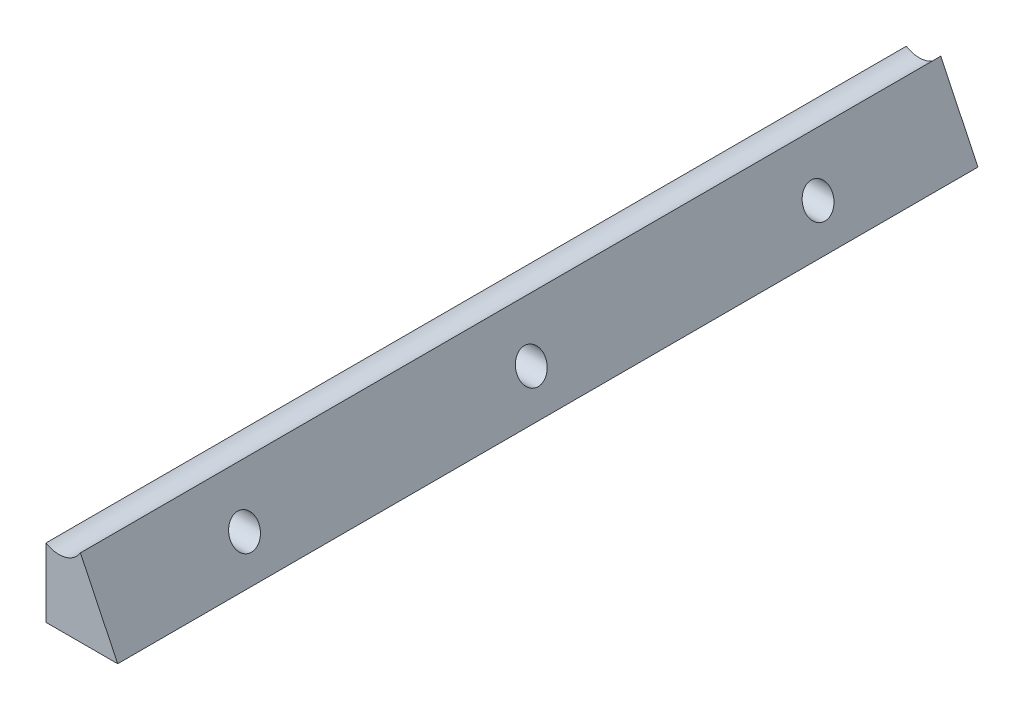
from build123d import *

# Parameters (mm, degrees)
BOSS_EXTRU_1_DEPTH = 150
TROU_TARAUD_M63_D  = 5


with BuildPart() as part:
    # Esquisse1 → Boss.-Extru.1 (new body)
    with BuildSketch(Plane.XY):
        with BuildLine():
            Line((0, 0), (12.5, 0))
            Line((12.5, 0), (6, 13.5))
            ThreePointArc((6, 13.5), (3.310660172, 11.507359313), (0, 12))
            Line((0, 12), (0, 0))
        make_face()
    extrude(amount=BOSS_EXTRU_1_DEPTH)

    # Trou taraudé M63 (through all)
    with Locations(Plane(origin=(0, 6, 25), x_dir=(0, 0, -1), z_dir=(-1, 0, 0))):
        with Locations((0, 0), (-50, 0), (-100, 0)):
            Hole(TROU_TARAUD_M63_D / 2)


solid = part.part
